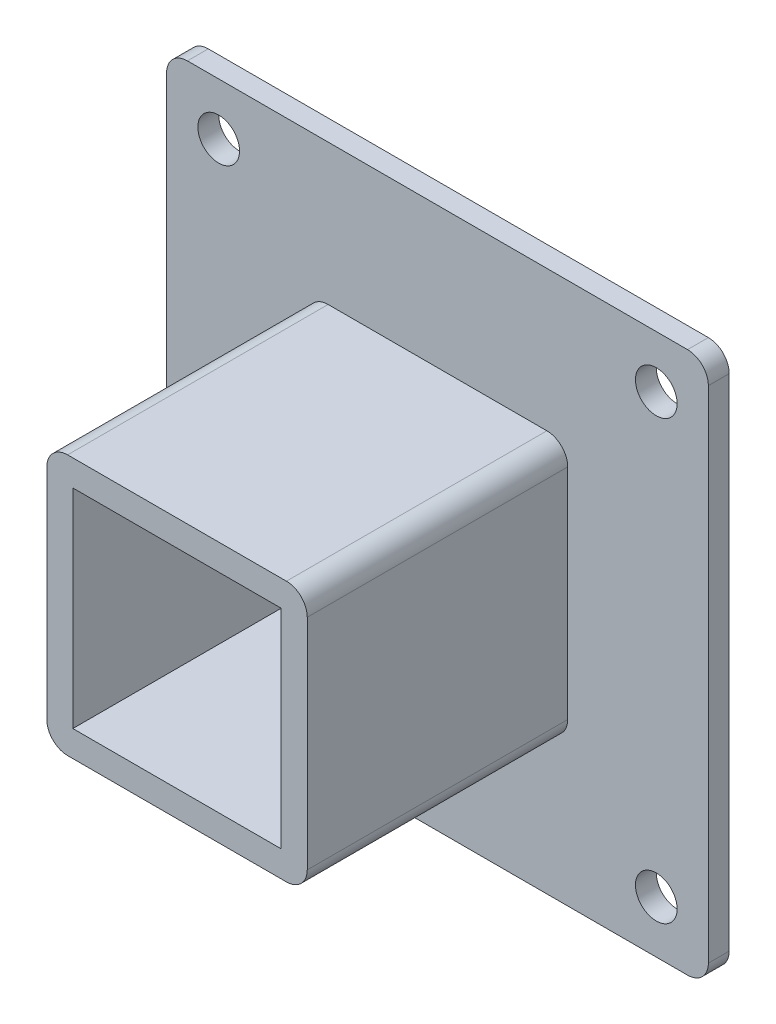
from build123d import *

# Parameters (mm, degrees)
SKETCH_1_W          = 25
SKETCH_1_H          = 25
SKETCH_1_W_2        = 20
SKETCH_1_H_2        = 20
EXTRUDE_1_DEPTH     = 25
SKETCH_3_W          = 52
SKETCH_3_H          = 52
EXTRUDE_2_DEPTH     = 2
SKETCH_4_W          = 20
SKETCH_4_H          = 20
CUT_EXTRUDE_1_DEPTH = 28
FILLET_1_R          = 2
FILLET_2_R          = 2
FILLET_3_R          = 2
FILLET_4_R          = 2
FILLET_5_R          = 2
FILLET_6_R          = 2
FILLET_7_R          = 2
FILLET_8_R          = 2
SKETCH_5_R          = 2
CUT_EXTRUDE_2_DEPTH = 28


with BuildPart() as part:
    # 草图1 → 凸台-拉伸1 (new body)
    with BuildSketch(Plane.XY):
        Rectangle(SKETCH_1_W, SKETCH_1_H)
        Rectangle(SKETCH_1_W_2, SKETCH_1_H_2, mode=Mode.SUBTRACT)
    extrude(amount=EXTRUDE_1_DEPTH)

    # 草图3 → 凸台-拉伸2 (add)
    with BuildSketch(Plane(origin=(0, 0, 0), x_dir=(-1, 0, 0), z_dir=(0, 0, -1))):
        Rectangle(SKETCH_3_W, SKETCH_3_H)
    extrude(amount=EXTRUDE_2_DEPTH)

    # 草图4 → 切除-拉伸1 (cut, through all)
    with BuildSketch(Plane(origin=(0, 0, -2), x_dir=(-1, 0, 0), z_dir=(0, 0, -1))):
        Rectangle(SKETCH_4_W, SKETCH_4_H)
    extrude(amount=-CUT_EXTRUDE_1_DEPTH, mode=Mode.SUBTRACT)

    # 圆角1
    fillet_1_edges = [part.edges().sort_by_distance(p)[0] for p in [
        (-26, 26, -1),
    ]]
    fillet(fillet_1_edges, radius=FILLET_1_R)

    # 圆角2
    fillet_2_edges = [part.edges().sort_by_distance(p)[0] for p in [
        (-26, -26, -1),
    ]]
    fillet(fillet_2_edges, radius=FILLET_2_R)

    # 圆角3
    fillet_3_edges = [part.edges().sort_by_distance(p)[0] for p in [
        (26, -26, -1),
    ]]
    fillet(fillet_3_edges, radius=FILLET_3_R)

    # 圆角4
    fillet_4_edges = [part.edges().sort_by_distance(p)[0] for p in [
        (26, 26, -1),
    ]]
    fillet(fillet_4_edges, radius=FILLET_4_R)

    # 圆角5
    fillet_5_edges = [part.edges().sort_by_distance(p)[0] for p in [
        (-12.5, -12.5, 12.5),
    ]]
    fillet(fillet_5_edges, radius=FILLET_5_R)

    # 圆角6
    fillet_6_edges = [part.edges().sort_by_distance(p)[0] for p in [
        (-12.5, 12.5, 12.5),
    ]]
    fillet(fillet_6_edges, radius=FILLET_6_R)

    # 圆角7
    fillet_7_edges = [part.edges().sort_by_distance(p)[0] for p in [
        (12.5, 12.5, 12.5),
    ]]
    fillet(fillet_7_edges, radius=FILLET_7_R)

    # 圆角8
    fillet_8_edges = [part.edges().sort_by_distance(p)[0] for p in [
        (12.5, -12.5, 12.5),
    ]]
    fillet(fillet_8_edges, radius=FILLET_8_R)

    # 草图5 → 切除-拉伸2 (cut, through all)
    with BuildSketch(Plane(origin=(0, 0, -2), x_dir=(-1, 0, 0), z_dir=(0, 0, -1))):
        with Locations((-21, 21)):
            Circle(SKETCH_5_R)
        with Locations((21, 21)):
            Circle(SKETCH_5_R)
        with Locations((-21, -21)):
            Circle(SKETCH_5_R)
        with Locations((21, -21)):
            Circle(SKETCH_5_R)
    extrude(amount=-CUT_EXTRUDE_2_DEPTH, mode=Mode.SUBTRACT)


solid = part.part
